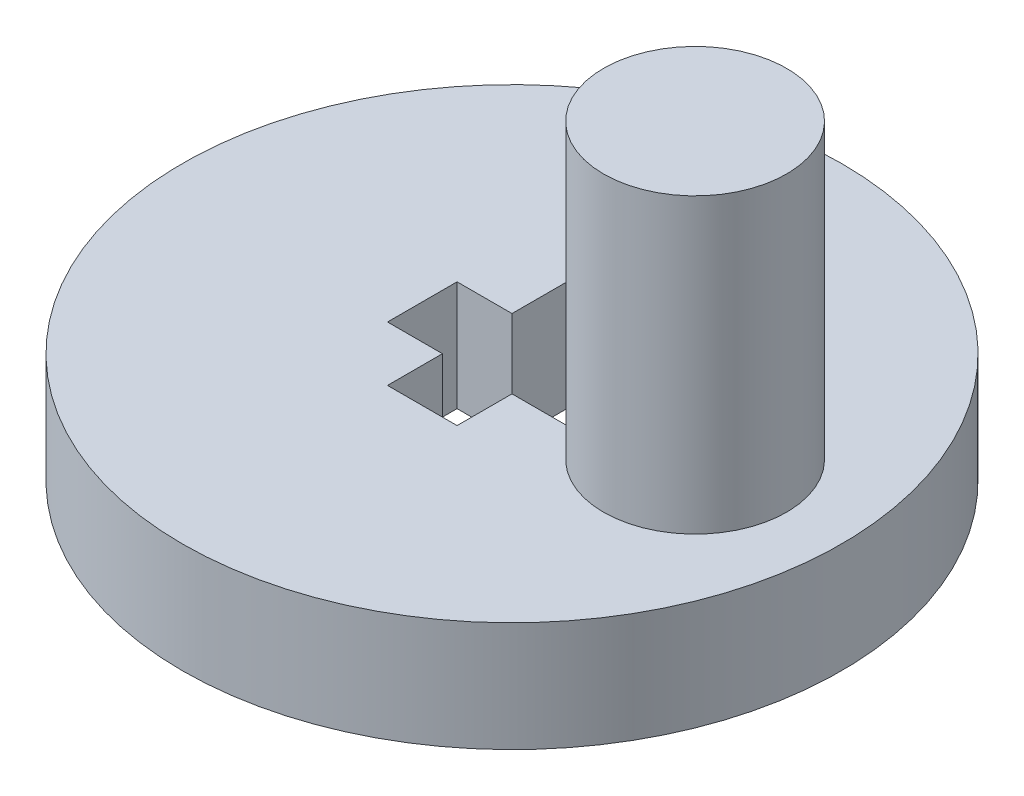
from build123d import *

# Parameters (mm, degrees)
SKETCH1_R           = 9
BOSS_EXTRUDE1_DEPTH = 3
SKETCH2_R           = 2.5
BOSS_EXTRUDE2_DEPTH = 8


with BuildPart() as part:
    # Sketch1 → Boss-Extrude1 (new body)
    with BuildSketch(Plane(origin=(0, 0, 0), x_dir=(1, 0, 0), z_dir=(0, 1, 0))):
        Circle(SKETCH1_R)
        Polygon((-2.45, 0.95), (-2.45, -0.95), (-0.95, -0.95), (-0.95, -2.45), (0.95, -2.45), (0.95, -0.95), (2.45, -0.95), (2.45, 0.95), (0.95, 0.95), (0.95, 2.45), (-0.95, 2.45), (-0.95, 0.95), align=None, mode=Mode.SUBTRACT)
    extrude(amount=BOSS_EXTRUDE1_DEPTH)

    # Sketch2 → Boss-Extrude2 (add)
    with BuildSketch(Plane(origin=(0, 3, 0), x_dir=(1, 0, 0), z_dir=(0, 1, 0))):
        with Locations((5, 0)):
            Circle(SKETCH2_R)
    extrude(amount=BOSS_EXTRUDE2_DEPTH)


solid = part.part
